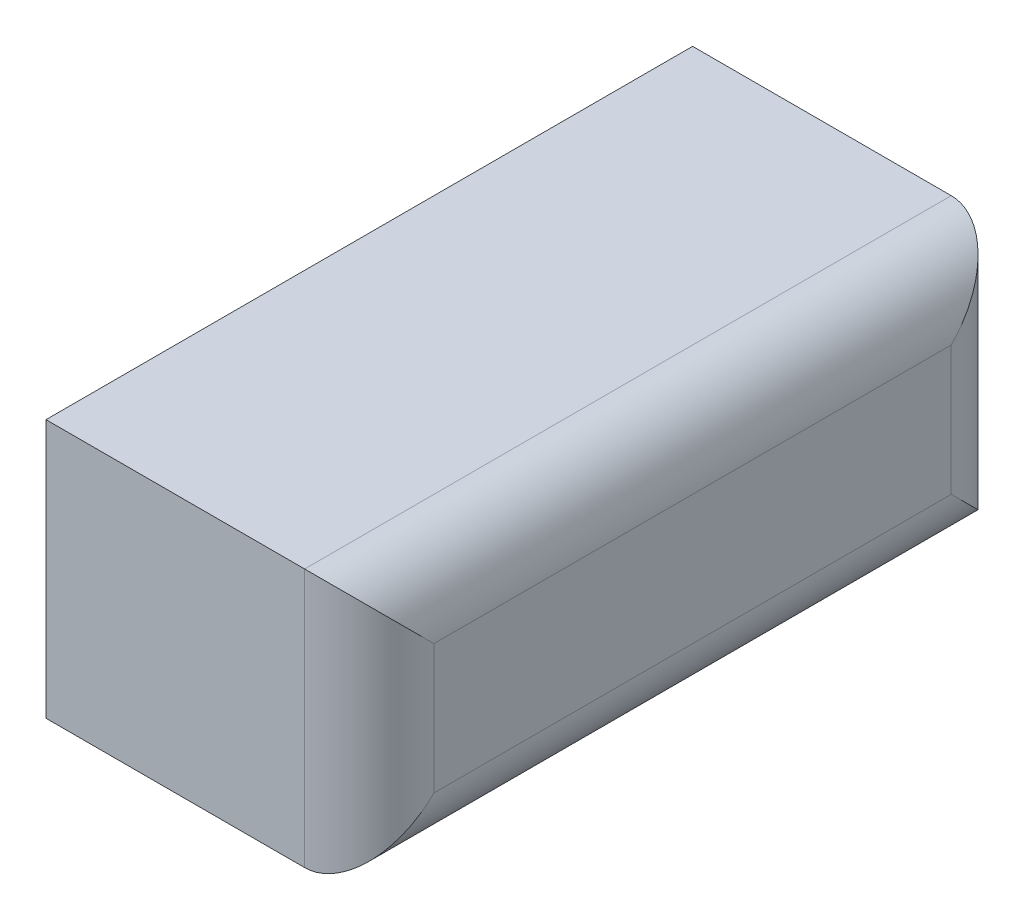
from build123d import *

# Parameters (mm, degrees)
ESQUISSE1_W      = 0.5
ESQUISSE1_H      = 1
EXTRUSION1_DEPTH = 0.4
CONG_1_R         = 0.1


with BuildPart() as part:
    # Esquisse1 → Extrusion1 (new body)
    with BuildSketch(Plane(origin=(0, 0, 0), x_dir=(1, 0, 0), z_dir=(0, 1, 0))):
        with Locations((0.25, 0.5)):
            Rectangle(ESQUISSE1_W, ESQUISSE1_H)
    extrude(amount=EXTRUSION1_DEPTH)

    # Congé1
    cong_1_edges = [part.edges().sort_by_distance(p)[0] for p in [
        (0.5, 0.4, -0.5),
        (0.5, 0, -0.5),
        (0.5, 0.2, -1),
        (0.5, 0.2, 0),
    ]]
    fillet(cong_1_edges, radius=CONG_1_R)


solid = part.part
